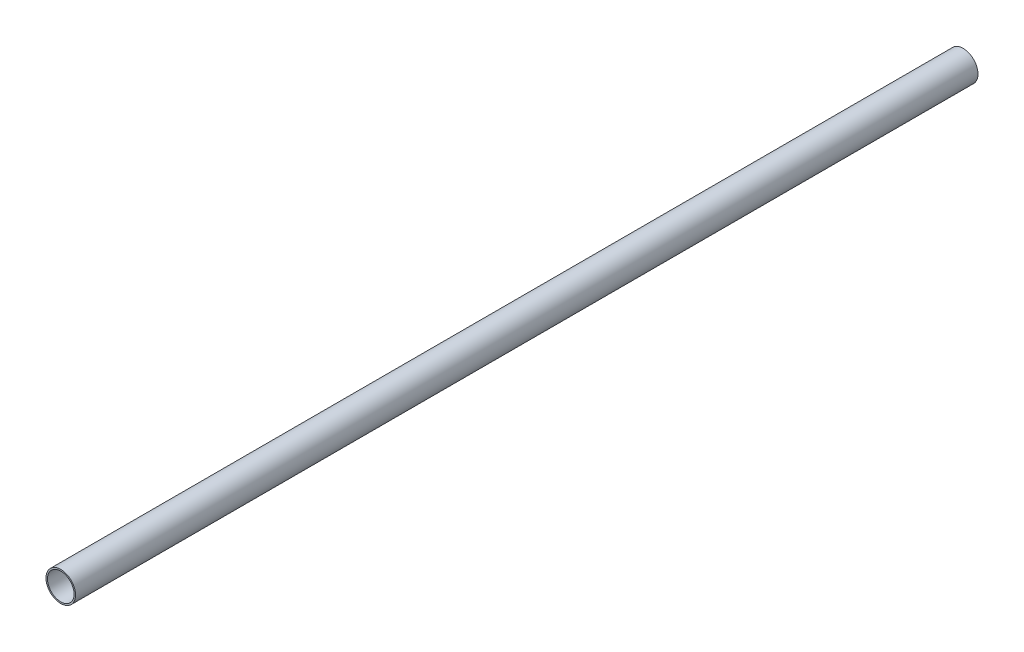
from build123d import *

# Parameters (mm, degrees)
SKETCH1_R           = 12.7
SKETCH1_R_2         = 11.43
BOSS_EXTRUDE1_DEPTH = 774.7


with BuildPart() as part:
    # Sketch1 → Boss-Extrude1 (new body)
    with BuildSketch(Plane.XY):
        Circle(SKETCH1_R)
        Circle(SKETCH1_R_2, mode=Mode.SUBTRACT)
    extrude(amount=BOSS_EXTRUDE1_DEPTH)


solid = part.part
